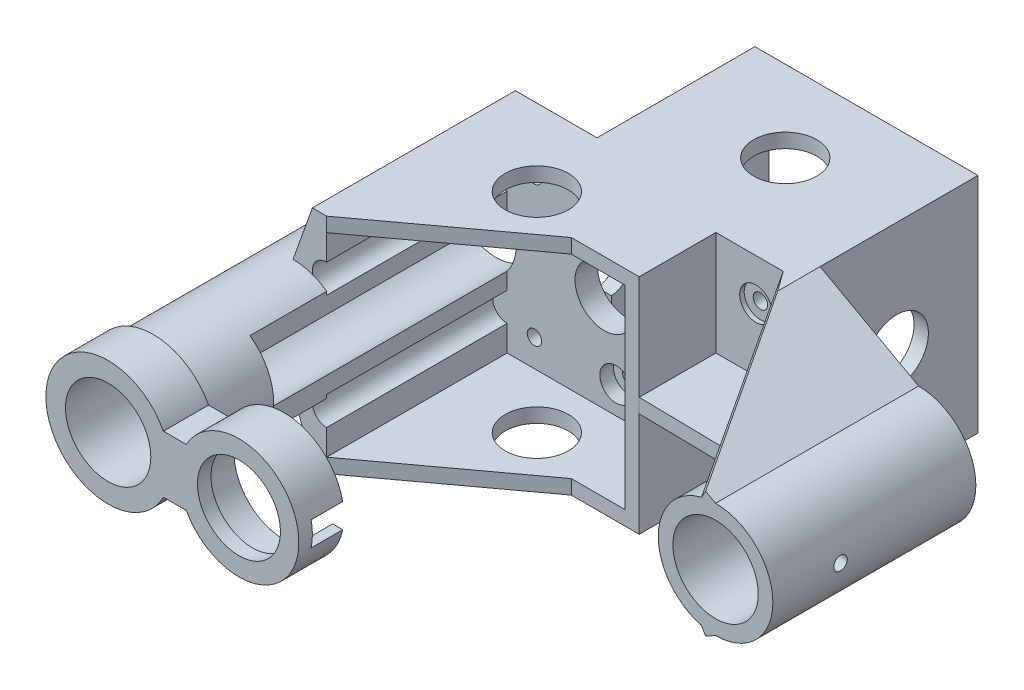
from build123d import *

# Parameters (mm, degrees)
SKETCH5_R       = 9.46
SKETCH5_R_2     = 1.6
EXTRUDE1_DEPTH  = 5
SKETCH6_R       = 9.46
EXTRUDE2_DEPTH  = 40
SKETCH7_W       = 49.45
SKETCH7_H       = 49.45
SKETCH7_W_2     = 43.1
SKETCH7_H_2     = 43.1
EXTRUDE3_DEPTH  = 35
EXTRUDE5_REACH  = 20.597
EXTRUDE6_REACH  = 20.597
SKETCH16_R      = 7
EXTRUDE9_DEPTH  = 49.45
EXTRUDE10_DEPTH = 17
SKETCH18_R      = 12.7
SKETCH18_R_2    = 9.46
EXTRUDE11_DEPTH = 14
SKETCH19_R      = 11.1
SKETCH19_R_2    = 9.46
EXTRUDE12_DEPTH = 7
SKETCH20_R      = 9.46
SKETCH20_R_2    = 9.2
EXTRUDE13_DEPTH = 3
EXTRUDE14_DEPTH = 15
SKETCH22_R      = 3.6
EXTRUDE15_DEPTH = 3
SKETCH23_R      = 3.6
EXTRUDE16_DEPTH = 3
SKETCH24_R      = 7
EXTRUDE17_DEPTH = 49.45
SKETCH25_R      = 6.5
EXTRUDE18_DEPTH = 5
EXTRUDE19_START = -25.300694
SKETCH26_R      = 1.5
EXTRUDE19_DEPTH = 119.050001
SKETCH27_R      = 3.6
EXTRUDE20_DEPTH = 1


with BuildPart() as part:
    # Sketch5 → Extrude1 (new body)
    with BuildSketch(Plane.XY):
        with BuildLine():
            Line((-21.825, -24.725), (0, -12.7))
            ThreePointArc((0, -12.7), (12.7, 0), (0, 12.7))
            Line((0, 12.7), (-21.825, 24.725))
            Line((-21.825, 24.725), (-89.375, 24.725))
            Line((-89.375, 24.725), (-93.65, 12.7))
            ThreePointArc((-93.65, 12.7), (-106.35, 0), (-93.65, -12.7))
            Line((-93.65, -12.7), (-89.375, -24.725))
            Line((-89.375, -24.725), (-21.825, -24.725))
        make_face()
        Circle(SKETCH5_R, mode=Mode.SUBTRACT)
        with Locations((-93.65, 0)):
            Circle(SKETCH5_R, mode=Mode.SUBTRACT)
        with Locations((-31.05, 15.5)):
            Circle(SKETCH5_R_2, mode=Mode.SUBTRACT)
        with Locations((-31.05, -15.5)):
            Circle(SKETCH5_R_2, mode=Mode.SUBTRACT)
        with Locations((-49.15, -15.5)):
            Circle(SKETCH5_R_2, mode=Mode.SUBTRACT)
        with Locations((-49.15, 15.5)):
            Circle(SKETCH5_R_2, mode=Mode.SUBTRACT)
        with Locations((-62.05, 15.5)):
            Circle(SKETCH5_R_2, mode=Mode.SUBTRACT)
        with Locations((-80.15, 15.5)):
            Circle(SKETCH5_R_2, mode=Mode.SUBTRACT)
        with Locations((-80.15, -15.5)):
            Circle(SKETCH5_R_2, mode=Mode.SUBTRACT)
        with Locations((-62.05, -15.5)):
            Circle(SKETCH5_R_2, mode=Mode.SUBTRACT)
    extrude(amount=EXTRUDE1_DEPTH)

    # Sketch6 → Extrude2 (add)
    with BuildSketch(Plane.XY.offset(5)):
        with BuildLine():
            Line((-39.925, 24.725), (-89.375, 24.725))
            Line((-89.375, 24.725), (-93.65, 12.7))
            ThreePointArc((-93.65, 12.7), (-106.35, 0), (-93.65, -12.7))
            Line((-93.65, -12.7), (-89.375, -24.725))
            Line((-89.375, -24.725), (-39.925, -24.725))
            Line((-39.925, -24.725), (-39.925, -1.585093616))
            Line((-39.925, -1.585093616), (-12.600693561, -1.585093616))
            ThreePointArc((-12.600693561, -1.585093616), (-9.51301391, -8.413831847), (-3.112651943, -12.312651943))
            Line((-3.112651943, -12.312651943), (-25, -24.725))
            Line((-25, -24.725), (-21.825, -24.725))
            Line((-21.825, -24.725), (0, -12.7))
            ThreePointArc((0, -12.7), (12.7, 0), (0, 12.7))
            Line((0, 12.7), (-21.825, 24.725))
            Line((-21.825, 24.725), (-25, 24.725))
            Line((-25, 24.725), (-3.112651943, 12.312651943))
            ThreePointArc((-3.112651943, 12.312651943), (-9.513885465, 8.41284633), (-12.601021697, 1.58248292))
            Line((-12.601021697, 1.58248292), (-39.925, 1.58248292))
            Line((-39.925, 1.58248292), (-39.925, 24.725))
        make_face()
        Circle(SKETCH6_R, mode=Mode.SUBTRACT)
        with BuildLine():
            Line((-86.2, -21.55), (-43.1, -21.55))
            Line((-43.1, -21.55), (-43.1, 21.55))
            Line((-43.1, 21.55), (-86.2, 21.55))
            Line((-86.2, 21.55), (-86.2, 15.891608363))
            ThreePointArc((-86.2, 15.891608363), (-89.375, 12.716608363), (-86.2, 9.541608363))
            Line((-86.2, 9.541608363), (-86.2, 5.830017153))
            ThreePointArc((-86.2, 5.830017153), (-103.11, 0), (-86.2, -5.830017153))
            Line((-86.2, -5.830017153), (-86.2, -9.508391637))
            ThreePointArc((-86.2, -9.508391637), (-89.375, -12.683391637), (-86.2, -15.858391637))
            Line((-86.2, -15.858391637), (-86.2, -21.55))
        make_face(mode=Mode.SUBTRACT)
    extrude(amount=EXTRUDE2_DEPTH)

    # Sketch7 → Extrude3 (add)
    with BuildSketch(Plane(origin=(0, 0, 0), x_dir=(-1, 0, 0), z_dir=(0, 0, -1))):
        with Locations((46.55, 0)):
            Rectangle(SKETCH7_W, SKETCH7_H)
        with Locations((46.55, 0)):
            Rectangle(SKETCH7_W_2, SKETCH7_H_2, mode=Mode.SUBTRACT)
    extrude(amount=EXTRUDE3_DEPTH)

    # Extrude5: up to this face of the body (flat: up to its plane)
    extrude5_end = Plane(part.part.faces().sort_by_distance((-10.9125, 18.7125, 22.5))[0])
    # Sketch12 → Extrude5 (cut, up to the picked face)
    with BuildSketch(Plane(origin=(4.5259255, 7.980803168, 0), x_dir=(0, 0, 1), z_dir=(-0.493298857, -0.869859895, 0)), mode=Mode.PRIVATE) as extrude5_sk1:
        Polygon((45, 8.781388226), (5, 33.943311626), (45, 33.943311626), align=None)
    extrude5_tool1 = split(extrude(extrude5_sk1.sketch, amount=-EXTRUDE5_REACH, mode=Mode.PRIVATE), bisect_by=extrude5_end, keep=Keep.BOTH, mode=Mode.PRIVATE)
    add(extrude5_tool1.solids().sort_by_distance((-17.704217, 20.587551, 31.666667))[0], mode=Mode.SUBTRACT)

    # Extrude6: up to this face of the body (flat: up to its plane)
    extrude6_end = Plane(part.part.faces().sort_by_distance((-10.9125, -18.7125, 22.5))[0])
    # Sketch13 → Extrude6 (cut, up to the picked face)
    with BuildSketch(Plane(origin=(4.5259255, -7.980803168, 0), x_dir=(0, 0, 1), z_dir=(-0.493298857, 0.869859895, 0)), mode=Mode.PRIVATE) as extrude6_sk1:
        Polygon((45, -8.781388226), (5, -33.943311626), (45, -33.943311626), align=None)
    extrude6_tool1 = split(extrude(extrude6_sk1.sketch, amount=-EXTRUDE6_REACH, mode=Mode.PRIVATE), bisect_by=extrude6_end, keep=Keep.BOTH, mode=Mode.PRIVATE)
    add(extrude6_tool1.solids().sort_by_distance((-17.704217, -20.587551, 31.666667))[0], mode=Mode.SUBTRACT)

    # Sketch16 → Extrude9 (cut)
    with BuildSketch(Plane.XZ.offset(24.725)):
        with Locations((-46.55, -17)):
            Circle(SKETCH16_R)
        with Locations((-67.618096531, 17)):
            Circle(SKETCH16_R)
        Polygon((-39.925, 22), (-16.781973348, 22.403360483), (-12.600693561, 29.053940018), (-12.600693561, 45), (-86.2, 45), (-54.981583076, 22), align=None)
    extrude(amount=-EXTRUDE9_DEPTH, mode=Mode.SUBTRACT)

    # Sketch17 → Extrude10 (add)
    with BuildSketch(Plane.XY.offset(45)):
        with BuildLine():
            Line((-86.2, 10.285305051), (-86.2, 5.830017153))
            ThreePointArc((-86.2, 5.830017153), (-103.11, 0), (-86.2, -5.830017153))
            Line((-86.2, -5.830017153), (-86.2, -10.285305051))
            ThreePointArc((-86.2, -10.285305051), (-89.146529591, -11.874710703), (-92.40601106, -12.638927625))
            ThreePointArc((-92.40601106, -12.638927625), (-106.334722718, -0.62274359), (-93.65, 12.7))
            ThreePointArc((-93.65, 12.7), (-89.734222565, 12.081253539), (-86.2, 10.285305051))
        make_face()
    extrude(amount=EXTRUDE10_DEPTH)

    # Sketch18 → Extrude11 (add)
    with BuildSketch(Plane.XY.offset(62)):
        with Locations((-93.65, 0)):
            Circle(SKETCH18_R)
        with Locations((-93.65, 0)):
            Circle(SKETCH18_R_2, mode=Mode.SUBTRACT)
    extrude(amount=EXTRUDE11_DEPTH)

    # Sketch19 → Extrude12 (add)
    with BuildSketch(Plane.XY.offset(76)):
        with BuildLine():
            Line((-81.398348387, -6.344577353), (-76.315821236, -6.344577353))
            ThreePointArc((-76.315821236, -6.344577353), (-51.370502761, 0), (-76.315821236, 6.344577353))
            Line((-76.315821236, 6.344577353), (-81.398348387, 6.344577353))
            ThreePointArc((-81.398348387, 6.344577353), (-107.446978982, 0), (-81.398348387, -6.344577353))
        make_face()
        with Locations((-64.65, 0)):
            Circle(SKETCH19_R, mode=Mode.SUBTRACT)
        with Locations((-93.65, 0)):
            Circle(SKETCH19_R_2, mode=Mode.SUBTRACT)
    extrude(amount=EXTRUDE12_DEPTH)

    # Sketch20 → Extrude13 (add)
    with BuildSketch(Plane.XY.offset(83)):
        with BuildLine():
            Line((-81.398348387, -6.344577353), (-76.315821236, -6.344577353))
            ThreePointArc((-76.315821236, -6.344577353), (-51.370502761, 0), (-76.315821236, 6.344577353))
            Line((-76.315821236, 6.344577353), (-81.398348387, 6.344577353))
            ThreePointArc((-81.398348387, 6.344577353), (-107.446978982, 0), (-81.398348387, -6.344577353))
        make_face()
        with Locations((-93.65, 0)):
            Circle(SKETCH20_R, mode=Mode.SUBTRACT)
        with Locations((-64.65, 0)):
            Circle(SKETCH20_R_2, mode=Mode.SUBTRACT)
    extrude(amount=EXTRUDE13_DEPTH)

    # Sketch21 → Extrude14 (cut)
    with BuildSketch(Plane.ZY.offset(43.1)):
        Polygon((76, 0), (76, -2.7), (83, -2.7), (83, 2.7), (76, 2.7), align=None)
    extrude(amount=EXTRUDE14_DEPTH, mode=Mode.SUBTRACT)

    # Sketch22 → Extrude15 (cut)
    with BuildSketch(Plane.XY.offset(5)):
        with Locations((-62.05, 15.5)):
            Circle(SKETCH22_R)
        with Locations((-62.05, -15.5)):
            Circle(SKETCH22_R)
    extrude(amount=-EXTRUDE15_DEPTH, mode=Mode.SUBTRACT)

    # Sketch23 → Extrude16 (cut)
    with BuildSketch(Plane(origin=(0, 0, 0), x_dir=(-1, 0, 0), z_dir=(0, 0, -1))):
        with Locations((49.15, 15.5)):
            Circle(SKETCH23_R)
        with Locations((49.15, -15.5)):
            Circle(SKETCH23_R)
    extrude(amount=-EXTRUDE16_DEPTH, mode=Mode.SUBTRACT)

    # Sketch24 → Extrude17 (cut)
    with BuildSketch(Plane.ZY.offset(71.275)):
        with Locations((-17, 0)):
            Circle(SKETCH24_R)
        with BuildLine():
            Line((0, 0), (0, 4))
            ThreePointArc((0, 4), (-4, 0), (0, -4))
            Line((0, -4), (0, 0))
        make_face()
    extrude(amount=-EXTRUDE17_DEPTH, mode=Mode.SUBTRACT)

    # Sketch25 → Extrude18 (cut)
    with BuildSketch(Plane(origin=(0, 0, 0), x_dir=(-1, 0, 0), z_dir=(0, 0, -1))):
        with Locations((46.55, 0)):
            Circle(SKETCH25_R)
        with Locations((64.65, 0)):
            Circle(SKETCH25_R)
    extrude(amount=-EXTRUDE18_DEPTH, mode=Mode.SUBTRACT)

    # Sketch26 → Extrude19 (cut)
    with BuildSketch(Plane.ZY.offset(12.600693561).offset(EXTRUDE19_START)):
        with Locations((30, 0)):
            Circle(SKETCH26_R)
    extrude(amount=EXTRUDE19_DEPTH, mode=Mode.SUBTRACT)

    # Sketch27 → Extrude20 (cut)
    with BuildSketch(Plane.XY.offset(5)):
        with Locations((-31.05, 15.5)):
            Circle(SKETCH27_R)
        with Locations((-31.05, -15.5)):
            Circle(SKETCH27_R)
    extrude(amount=-EXTRUDE20_DEPTH, mode=Mode.SUBTRACT)


solid = part.part
